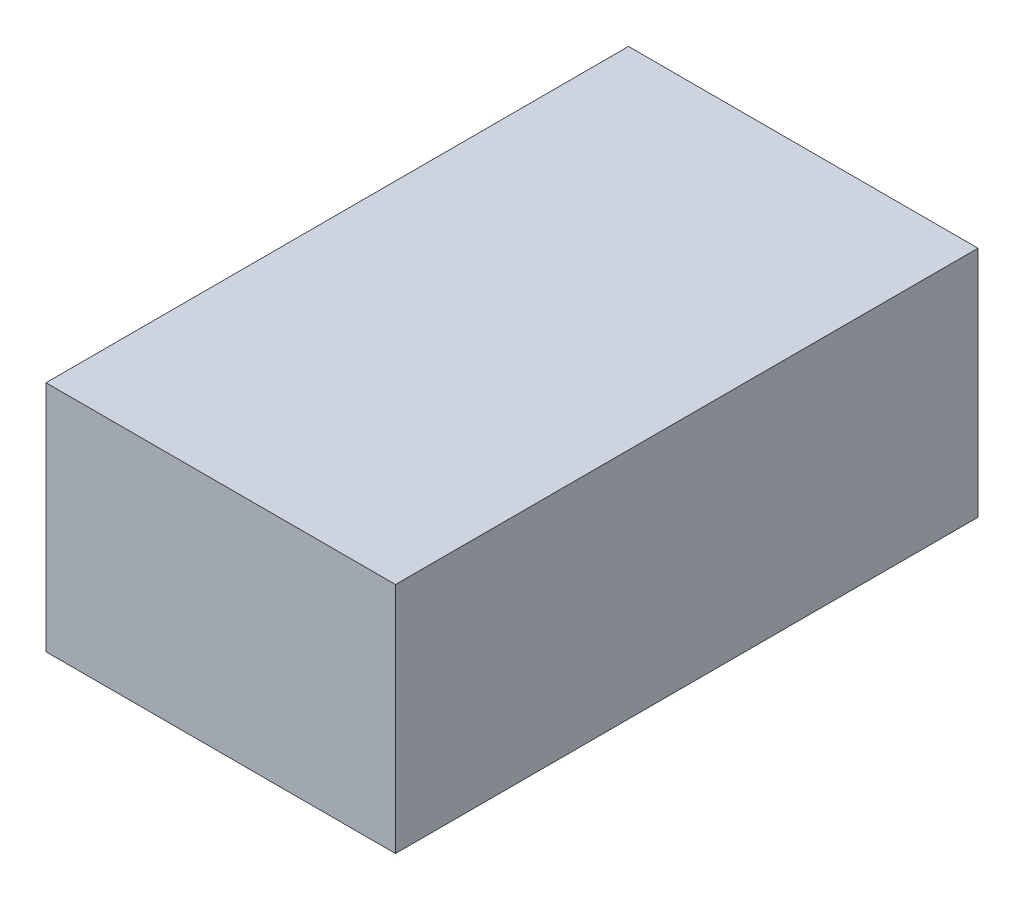
from build123d import *

# Parameters (mm, degrees)
BASES_W    = 0.6
BASES_H    = 1
BASE_DEPTH = 0.4


with BuildPart() as part:
    # BaseS → Base (new body)
    with BuildSketch(Plane(origin=(0, 0, 0), x_dir=(1, 0, 0), z_dir=(0, 1, 0))):
        Rectangle(BASES_W, BASES_H)
    extrude(amount=BASE_DEPTH)


solid = part.part
